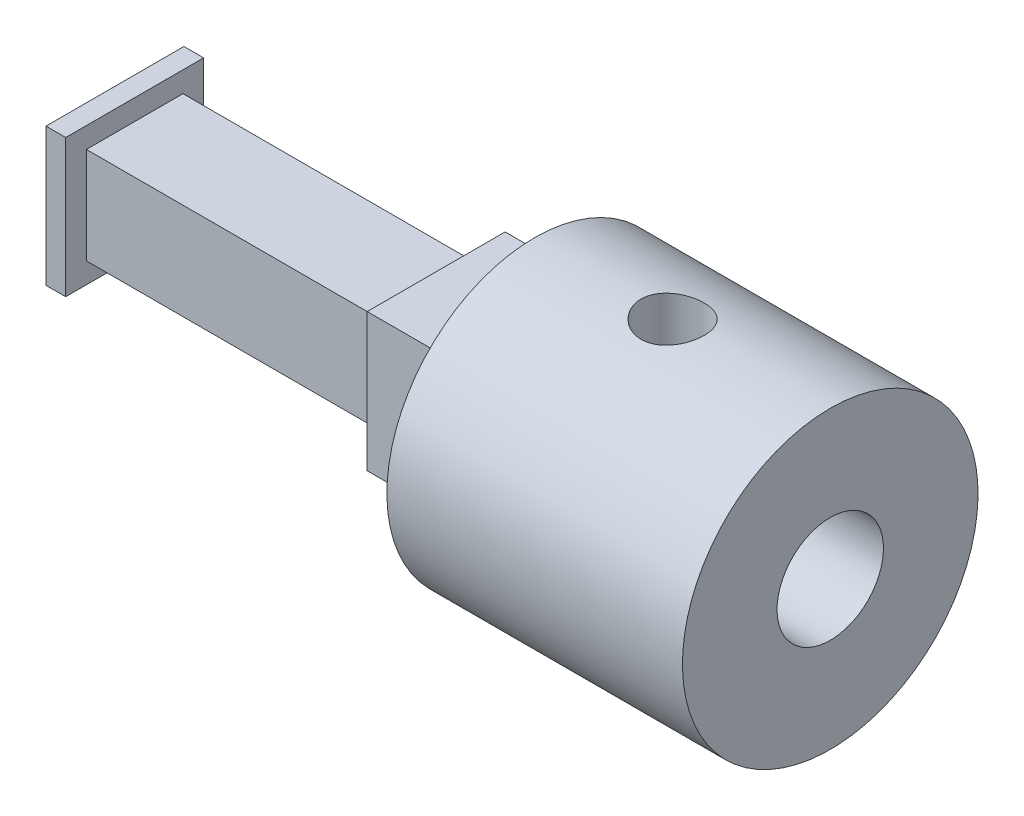
from build123d import *

# Parameters (mm, degrees)
SKETCH2_W           = 15
SKETCH2_H           = 7.5
SKETCH3_R           = 2.7
CUT_EXTRUDE1_DEPTH  = 10
SKETCH5_R           = 1.6
CUT_EXTRUDE2_DEPTH  = 11
SKETCH6_W           = 7
SKETCH6_H           = 7
BOSS_EXTRUDE1_DEPTH = 5
SKETCH7_W           = 4.9
SKETCH7_H           = 4.9
BOSS_EXTRUDE2_DEPTH = 15.3
SKETCH8_W           = 7
SKETCH8_H           = 7
BOSS_EXTRUDE3_DEPTH = 1


with BuildPart() as part:
    # Sketch2 → Revolve1 (revolve)
    with BuildSketch(Plane.XY):
        with Locations((7.5, 3.75)):
            Rectangle(SKETCH2_W, SKETCH2_H)
    revolve(axis=Axis((15, 0, 0), (-1, 0, 0)))

    # Sketch3 → Cut-Extrude1 (cut)
    with BuildSketch(Plane(origin=(15, 0, 0), x_dir=(0, 0, -1), z_dir=(1, 0, 0))):
        Circle(SKETCH3_R)
    extrude(amount=-CUT_EXTRUDE1_DEPTH, mode=Mode.SUBTRACT)

    # Sketch5 → Cut-Extrude2 (cut)
    with BuildSketch(Plane(origin=(0, 0, 0), x_dir=(1, 0, 0), z_dir=(0, 1, 0))):
        with Locations((7, 0)):
            Circle(SKETCH5_R)
    extrude(amount=CUT_EXTRUDE2_DEPTH, mode=Mode.SUBTRACT)

    # Sketch6 → Boss-Extrude1 (add)
    with BuildSketch(Plane.ZY):
        Rectangle(SKETCH6_W, SKETCH6_H)
    extrude(amount=BOSS_EXTRUDE1_DEPTH)

    # Sketch7 → Boss-Extrude2 (add)
    with BuildSketch(Plane.ZY.offset(5)):
        Rectangle(SKETCH7_W, SKETCH7_H)
    extrude(amount=BOSS_EXTRUDE2_DEPTH)

    # Sketch8 → Boss-Extrude3 (add)
    with BuildSketch(Plane.ZY.offset(20.3)):
        Rectangle(SKETCH8_W, SKETCH8_H)
    extrude(amount=BOSS_EXTRUDE3_DEPTH)


solid = part.part
